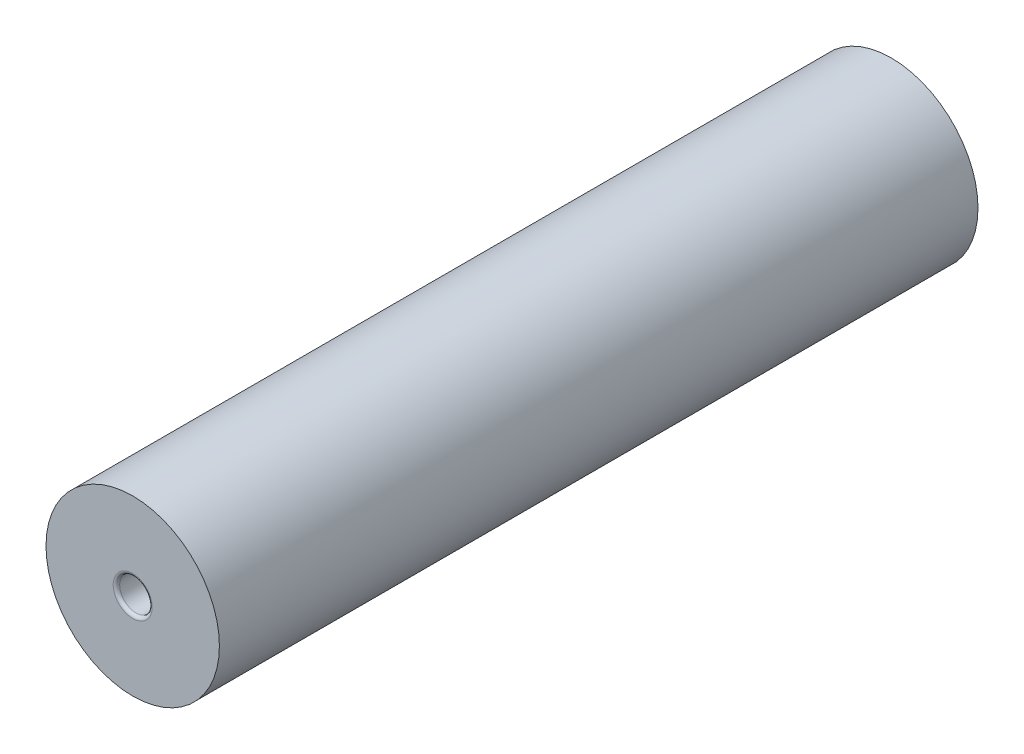
from build123d import *

# Parameters (mm, degrees)
SKETCH_1_R          = 8
EXTRUDE_1_DEPTH     = 70
SKETCH_6_R          = 1.5
CUT_EXTRUDE_1_DEPTH = 71
FILLET_1_R          = 0.3


with BuildPart() as part:
    # 草图1 → 凸台-拉伸1 (new body)
    with BuildSketch(Plane.XY):
        Circle(SKETCH_1_R)
    extrude(amount=-EXTRUDE_1_DEPTH)

    # 草图6 → 切除-拉伸1 (cut, through all)
    with BuildSketch(Plane.XY):
        Circle(SKETCH_6_R)
    extrude(amount=-CUT_EXTRUDE_1_DEPTH, mode=Mode.SUBTRACT)

    # 圆角1
    fillet_1_edges = [part.edges().sort_by_distance(p)[0] for p in [
        (-1.5, 0, -70),
        (-1.5, 0, 0),
    ]]
    fillet(fillet_1_edges, radius=FILLET_1_R)


solid = part.part
